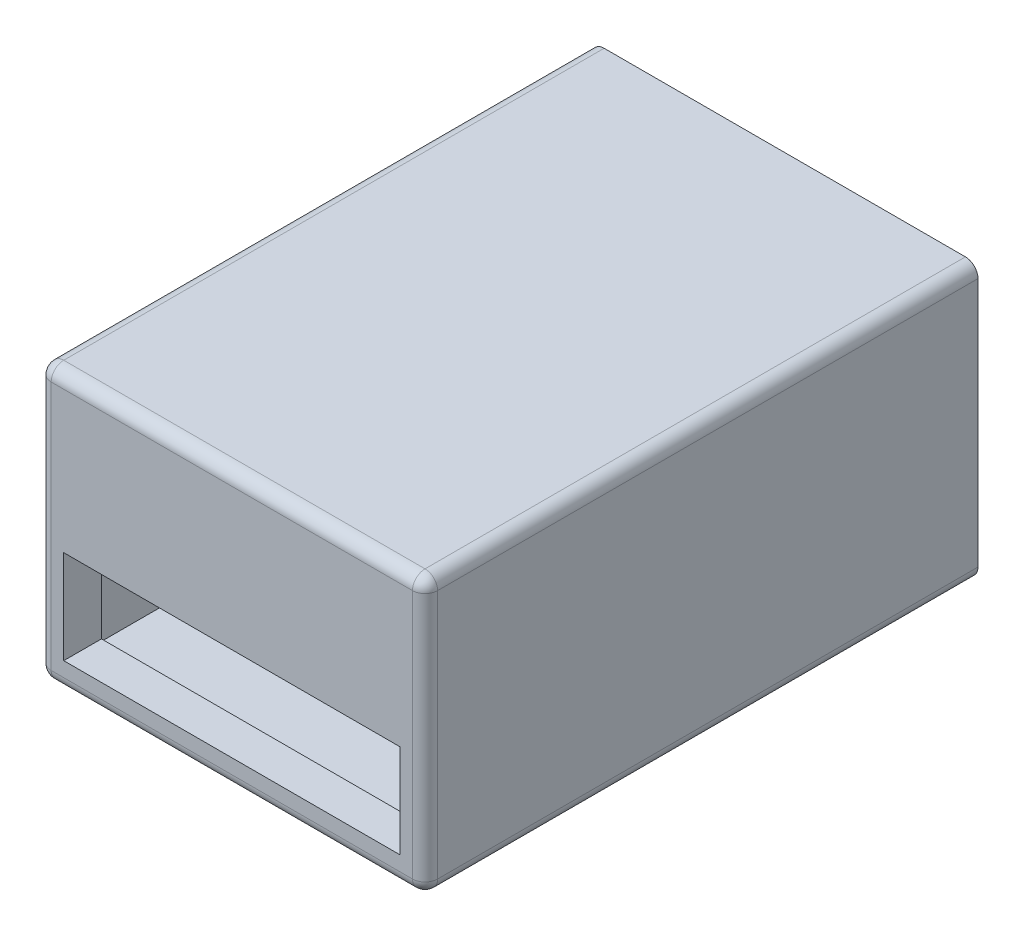
from build123d import *

# Parameters (mm, degrees)
ESQUISSE1_W             = 61.5
ESQUISSE1_H             = 43.75
BOSS_EXTRU_1_DEPTH      = 88
ENL_V_MAT_EXTRU_4_REACH = 90
ESQUISSE3_W             = 53.5
ESQUISSE3_H             = 14.889849441
ESQUISSE6_W             = 57.502648101
ESQUISSE6_H             = 39.75
ENL_V_MAT_EXTRU_5_DEPTH = 82
CONG_4_R                = 2
ESQUISSE7_R             = 1.5
BOSS_EXTRU_2_DEPTH      = 5.2
ESQUISSE8_R             = 1.5
BOSS_EXTRU_3_DEPTH      = 5.2


with BuildPart() as part:
    # Esquisse1 → Boss.-Extru.1 (new body)
    with BuildSketch(Plane.XY):
        with Locations((-0.850502513, 12.751256281)):
            Rectangle(ESQUISSE1_W, ESQUISSE1_H)
    extrude(amount=BOSS_EXTRU_1_DEPTH)

    # Esquisse3 → Enlèv. mat.-Extru.4 (cut, up to next)
    with BuildSketch(Plane.XY.offset(88), mode=Mode.PRIVATE) as enl_v_mat_extru_4_sk1:
        with Locations((-0.850502513, 2.663299217)):
            Rectangle(ESQUISSE3_W, ESQUISSE3_H)
    enl_v_mat_extru_4_tool1 = extrude(enl_v_mat_extru_4_sk1.sketch, amount=-ENL_V_MAT_EXTRU_4_REACH, mode=Mode.PRIVATE) & part.part
    add(enl_v_mat_extru_4_tool1.solids().sort_by_distance((-0.850503, 2.663299, 88))[0], mode=Mode.SUBTRACT)

    # Esquisse6 → Enlèv. mat.-Extru.5 (cut)
    with BuildSketch(Plane(origin=(0, 0, 0), x_dir=(-1, 0, 0), z_dir=(0, 0, -1))):
        with Locations((0.849178462, 12.751256281)):
            Rectangle(ESQUISSE6_W, ESQUISSE6_H)
    extrude(amount=-ENL_V_MAT_EXTRU_5_DEPTH, mode=Mode.SUBTRACT)

    # Congé4
    cong_4_edges = [part.edges().sort_by_distance(p)[0] for p in [
        (29.899497487, 12.751256281, 88),
        (-0.850502513, 34.626256281, 88),
        (-31.600502513, 12.751256281, 88),
        (-31.600502513, 34.626256281, 44),
        (29.899497487, 34.626256281, 44),
        (29.899497487, -9.123743719, 44),
        (-31.600502513, -9.123743719, 44),
        (-0.850502513, -9.123743719, 88),
    ]]
    fillet(cong_4_edges, radius=CONG_4_R)

    # Esquisse7 → Boss.-Extru.2 (add)
    with BuildSketch(Plane(origin=(0, -7.123743719, 0), x_dir=(1, 0, 0), z_dir=(0, 1, 0))):
        with Locations((18.002145588, -9.4)):
            Circle(ESQUISSE7_R)
    extrude(amount=BOSS_EXTRU_2_DEPTH)

    # Esquisse8 → Boss.-Extru.3 (add)
    with BuildSketch(Plane(origin=(0, -7.123743719, 0), x_dir=(1, 0, 0), z_dir=(0, 1, 0))):
        with Locations((-9.850502513, -9.5)):
            Circle(ESQUISSE8_R)
    extrude(amount=BOSS_EXTRU_3_DEPTH)


solid = part.part
